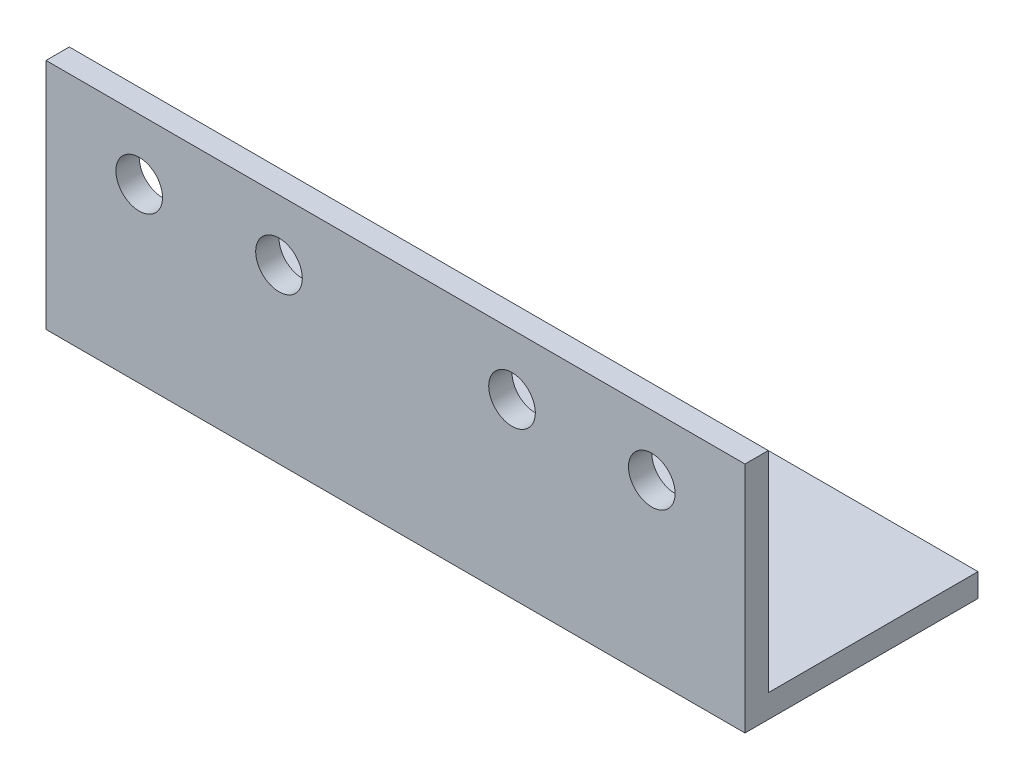
from build123d import *

# Parameters (mm, degrees)
EXTRUDE_1_DEPTH     = 150
SKETCH_2_R          = 5
CUT_EXTRUDE_1_DEPTH = 51
SKETCH_3_R          = 5
CUT_EXTRUDE_2_DEPTH = 51


with BuildPart() as part:
    # Эскиз1 → Вытянуть-Тонкостенный1 (new body)
    with BuildSketch(Plane(origin=(0, 0, 0), x_dir=(0, 0, -1), z_dir=(1, 0, 0))):
        Polygon((50, 0), (0, 0), (0, 50), (5, 50), (5, 5), (50, 5), align=None)
    extrude(amount=EXTRUDE_1_DEPTH)

    # Эскиз2 → Вырез-Вытянуть1 (cut, through all)
    with BuildSketch(Plane.XY):
        with Locations((20, 37)):
            Circle(SKETCH_2_R)
        with Locations((50, 37)):
            Circle(SKETCH_2_R)
        with Locations((100, 37)):
            Circle(SKETCH_2_R)
        with Locations((130, 37)):
            Circle(SKETCH_2_R)
    extrude(amount=-CUT_EXTRUDE_1_DEPTH, mode=Mode.SUBTRACT)

    # Эскиз3 → Вырез-Вытянуть2 (cut, through all)
    with BuildSketch(Plane.XZ):
        with Locations((130, -18)):
            Circle(SKETCH_3_R)
        with Locations((100, -18)):
            Circle(SKETCH_3_R)
        with Locations((50, -18)):
            Circle(SKETCH_3_R)
        with Locations((20, -18)):
            Circle(SKETCH_3_R)
    extrude(amount=-CUT_EXTRUDE_2_DEPTH, mode=Mode.SUBTRACT)


solid = part.part
